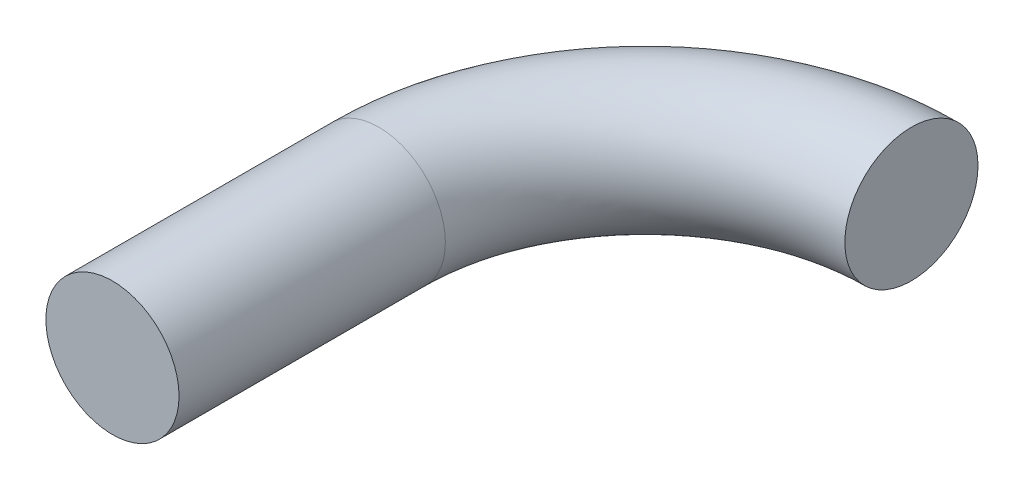
from build123d import *

# Parameters (mm, degrees)
SKETCH1_R = 12.7


with BuildPart() as part:
    # Sweep1: sweep along a path in Sketch2
    with BuildLine(Plane(origin=(0, 0, 0), x_dir=(1, 0, 0), z_dir=(0, 1, 0))) as sweep1_path:
        Line((0, 0), (0, 50.8))
        ThreePointArc((0, 50.8), (14.878975516, 86.721024484), (50.8, 101.6))
    # Sketch1 → Sweep1 (sweep)
    with BuildSketch(Plane.XY):
        Circle(SKETCH1_R)
    sweep(path=sweep1_path.line)


solid = part.part
